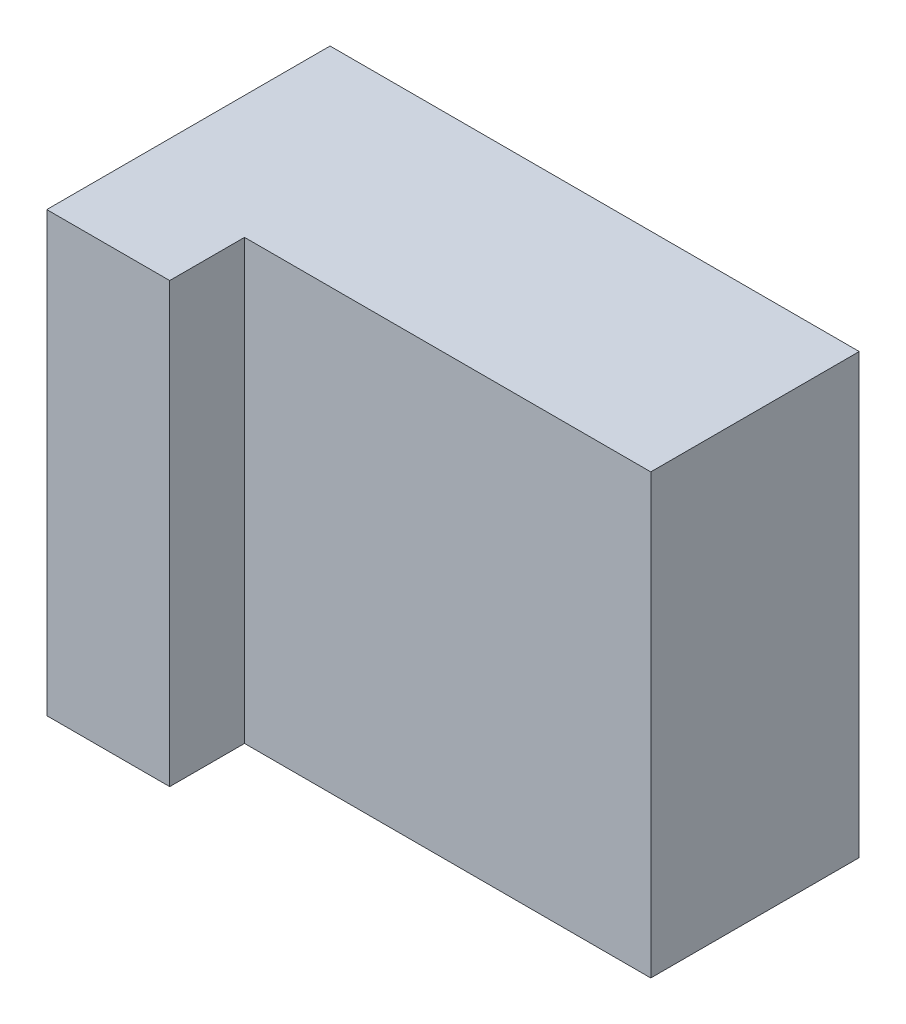
from build123d import *

# Parameters (mm, degrees)
BOSS_EXTRU_1_DEPTH = 52
ESQUISSE2_W        = 22
ESQUISSE2_H        = 82
BOSS_EXTRU_2_DEPTH = 1
ESQUISSE3_W        = 18
ESQUISSE3_H        = 82
BOSS_EXTRU_3_DEPTH = 1
BOSS_EXTRU_4_START = -1
BOSS_EXTRU_4_DEPTH = 76
ESQUISSE6_W        = 39
ESQUISSE6_H        = 82
BOSS_EXTRU_5_DEPTH = 1


with BuildPart() as part:
    # Esquisse1 → Boss.-Extru.1 (new body)
    with BuildSketch(Plane.XY):
        Polygon((22, 82), (22, 81), (21, 81), (1, 81), (1, 1), (21, 1), (22, 1), (22, 0), (0, 0), (0, 82), align=None)
    extrude(amount=BOSS_EXTRU_1_DEPTH)

    # Esquisse2 → Boss.-Extru.2 (add)
    with BuildSketch(Plane.XY.offset(52)):
        with Locations((11, 41)):
            Rectangle(ESQUISSE2_W, ESQUISSE2_H)
    extrude(amount=BOSS_EXTRU_2_DEPTH)

    # Esquisse3 → Boss.-Extru.3 (add)
    with BuildSketch(Plane(origin=(22, 0, 0), x_dir=(0, 0, -1), z_dir=(1, 0, 0))):
        with Locations((-44, 41)):
            Rectangle(ESQUISSE3_W, ESQUISSE3_H)
    extrude(amount=BOSS_EXTRU_3_DEPTH)

    # Esquisse5 → Boss.-Extru.4 (add)
    with BuildSketch(Plane(origin=(23, 0, 0), x_dir=(0, 0, -1), z_dir=(1, 0, 0)).offset(BOSS_EXTRU_4_START)):
        Polygon((-39, 0), (0, 0), (0, 1), (-35, 1), (-35, 81), (0, 81), (0, 82), (-39, 82), align=None)
    extrude(amount=BOSS_EXTRU_4_DEPTH)

    # Esquisse6 → Boss.-Extru.5 (add)
    with BuildSketch(Plane(origin=(98, 0, 0), x_dir=(0, 0, -1), z_dir=(1, 0, 0))):
        with Locations((-19.5, 41)):
            Rectangle(ESQUISSE6_W, ESQUISSE6_H)
    extrude(amount=BOSS_EXTRU_5_DEPTH)


solid = part.part
